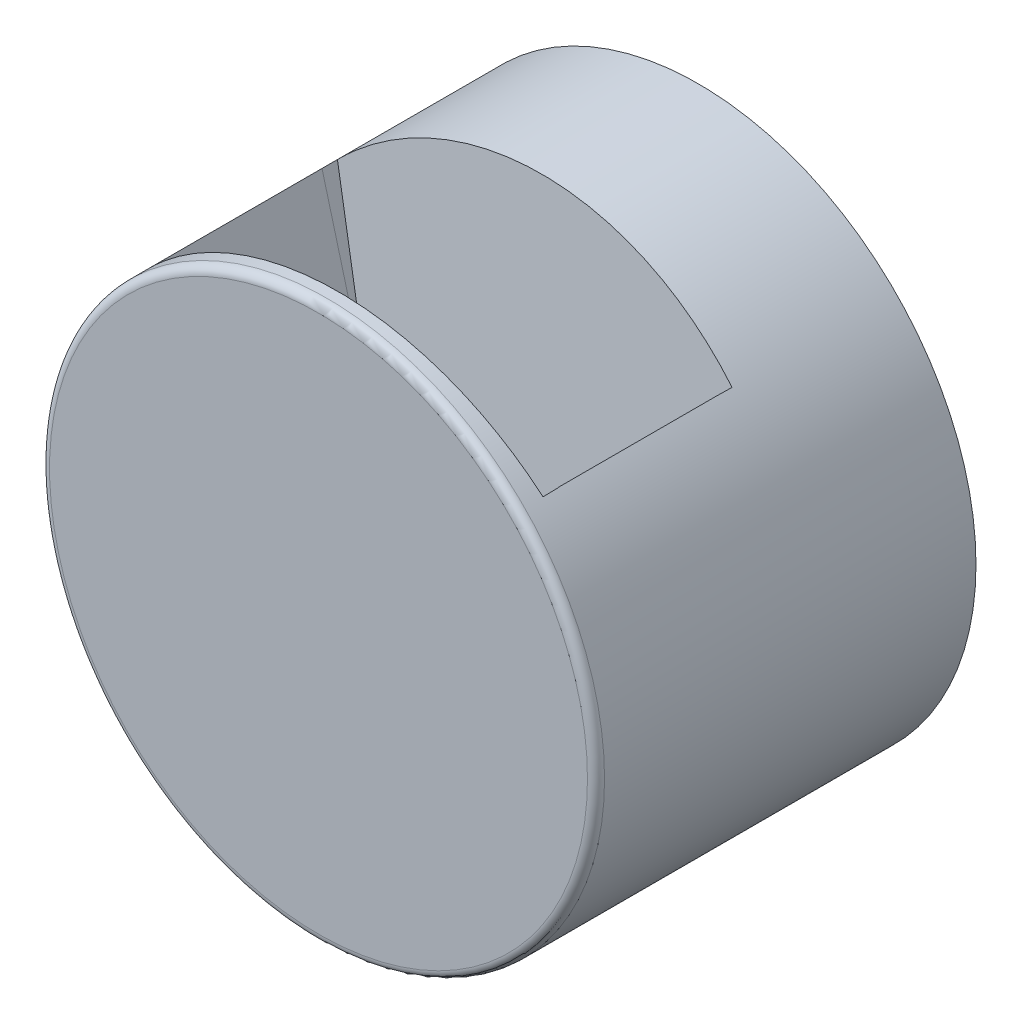
from build123d import *

# Parameters (mm, degrees)
SKETCH_2_R           = 32.5
EXTRUDE_1_DEPTH      = 3
EXTRUDE_START        = 43.5
SKETCH_3_R           = 32.5
SKETCH_3_R_2         = 30.5
EXTRUDE_2_DEPTH      = 43.5
SKETCH_4_W           = 35
SKETCH_4_H           = 18.5
CUT_EXTRUDE_1_DEPTH  = 52
EXTRUDE_3_REACH      = 93.83
EXTRUDE_3_END_RADIUS = 30.5
SKETCH_5_W           = 41
SKETCH_5_H           = 22.5
SKETCH_5_W_2         = 35
SKETCH_5_H_2         = 18.5
SKETCH_9_W           = 43.61428081
SKETCH_9_H           = 23.224697296
CUT_EXTRUDE_2_DEPTH  = 2
EXTRUDE_4_DEPTH      = 22.5
SKETCH_11_W          = 18.5
SKETCH_11_H          = 36.291622976
CUT_REVOLVE_1_ANGLE  = 15
SKETCH_12_W          = 18.5
SKETCH_12_H          = 37.014975327
CUT_REVOLVE_2_ANGLE  = 15
CUT_REVOLVE_3_ANGLE  = 5
CUT_REVOLVE_4_ANGLE  = 5
EXTRUDE_START_2      = 3
EXTRUDE_5_DEPTH      = 3
SKETCH_17_W          = 36.670628391
SKETCH_17_H          = 24.683517756
CUT_EXTRUDE_3_DEPTH  = 3
CHAMFER_1_SIZE       = 4
FILLET_1_R           = 1
EXTRUDE_6_REACH      = 67.382
SKETCH_18_R          = 3
SKETCH_19_R          = 3
EXTRUDE_7_DEPTH      = 18
SKETCH_20_R          = 0.95
CUT_EXTRUDE_4_DEPTH  = 10
SKETCH_21_R          = 44.197984087
CUT_EXTRUDE_5_DEPTH  = 2


with BuildPart() as part:
    # 草图2 → 凸台-拉伸1 (new body)
    with BuildSketch(Plane.XY.offset(76.5)):
        Circle(SKETCH_2_R)
    extrude(amount=EXTRUDE_1_DEPTH)

    # 草图3 → 凸台-拉伸2 (add)
    with BuildSketch(Plane(origin=(0, 0, 76.5), x_dir=(-1, 0, 0), z_dir=(0, 0, -1)).offset(EXTRUDE_START)):
        Circle(SKETCH_3_R)
        Circle(SKETCH_3_R_2, mode=Mode.SUBTRACT)
    extrude(amount=-EXTRUDE_2_DEPTH)

    # 草图4 → 切除-拉伸1 (cut)
    with BuildSketch(Plane(origin=(0, 0, 0), x_dir=(1, 0, 0), z_dir=(0, 1, 0))):
        with Locations((0, -65.25)):
            Rectangle(SKETCH_4_W, SKETCH_4_H)
    extrude(amount=CUT_EXTRUDE_1_DEPTH, mode=Mode.SUBTRACT)

    # 凸台-拉伸3: up to this cylinder (the profile starts inside it)
    extrude_3_end = Plane(origin=(0, 0, 54.46768), z_dir=(0, 0, 1)) * Cylinder(EXTRUDE_3_END_RADIUS, 249.66, mode=Mode.PRIVATE)
    # 草图5 → 凸台-拉伸3 (add, up to the surface)
    with BuildSketch(Plane(origin=(0, 0, 0), x_dir=(1, 0, 0), z_dir=(0, 1, 0)), mode=Mode.PRIVATE) as extrude_3_sk1:
        with Locations((0, -65.25)):
            Rectangle(SKETCH_5_W, SKETCH_5_H)
        with Locations((0, -65.25)):
            Rectangle(SKETCH_5_W_2, SKETCH_5_H_2, mode=Mode.SUBTRACT)
    extrude_3_tool1 = extrude(extrude_3_sk1.sketch, amount=EXTRUDE_3_REACH, mode=Mode.PRIVATE) & extrude_3_end
    add(extrude_3_tool1.solids().sort_by_distance((0, 0, 54.46768))[0])

    # 草图9 → 切除-拉伸2 (cut)
    with BuildSketch(Plane.XZ):
        with Locations((0, 64.887651352)):
            Rectangle(SKETCH_9_W, SKETCH_9_H)
    extrude(amount=-CUT_EXTRUDE_2_DEPTH, mode=Mode.SUBTRACT)

    # 草图10 → 凸台-拉伸4 (add)
    with BuildSketch(Plane(origin=(0, 0, 54), x_dir=(-1, 0, 0), z_dir=(0, 0, -1))):
        with BuildLine():
            Line((20.5, 2), (30.434355587, 2))
            ThreePointArc((30.434355587, 2), (27.468053538, 13.257301189), (20.5, 22.583179581))
            Line((20.5, 22.583179581), (20.5, 2))
        make_face()
        with BuildLine():
            Line((-20.5, 2), (-30.434355587, 2))
            ThreePointArc((-30.434355587, 2), (-27.468053538, 13.257301189), (-20.5, 22.583179581))
            Line((-20.5, 22.583179581), (-20.5, 2))
        make_face()
    extrude(amount=-EXTRUDE_4_DEPTH)

    # 草图11 → 切除-旋转1 (revolve, cut)
    with BuildSketch(Plane.ZY.offset(-17.5)):
        with Locations((65.25, 20.145811488)):
            Rectangle(SKETCH_11_W, SKETCH_11_H)
    revolve(axis=Axis((17.5, 2, 81.98075626), (0, 0, -1)), revolution_arc=CUT_REVOLVE_1_ANGLE, mode=Mode.SUBTRACT)

    # 草图12 → 切除-旋转2 (revolve, cut)
    with BuildSketch(Plane(origin=(-17.5, 0, 0), x_dir=(0, 0, -1), z_dir=(1, 0, 0))):
        with Locations((-65.25, 20.507487664)):
            Rectangle(SKETCH_12_W, SKETCH_12_H)
    revolve(axis=Axis((-17.5, 2, 82.239096386), (0, 0, 1)), revolution_arc=CUT_REVOLVE_2_ANGLE, mode=Mode.SUBTRACT)

    # 草图13 → 切除-旋转3 (revolve, cut)
    with BuildSketch(Plane.XY.offset(56)):
        Polygon((-17.5, 2), (17.5, 2), (26.341893189, 34.998394615), (-26.341893189, 34.998394615), align=None)
    revolve(axis=Axis((-38.580818274, 2, 56), (-1, 0, 0)), revolution_arc=CUT_REVOLVE_3_ANGLE, mode=Mode.SUBTRACT)

    # 草图14 → 切除-旋转4 (revolve, cut)
    with BuildSketch(Plane(origin=(0, 0, 74.5), x_dir=(-1, 0, 0), z_dir=(0, 0, -1))):
        Polygon((17.5, 2), (-17.5, 2), (-26.592656258, 35.805125046), (26.592656258, 35.805125046), align=None)
    revolve(axis=Axis((-42.793281967, 2, 74.5), (1, 0, 0)), revolution_arc=CUT_REVOLVE_4_ANGLE, mode=Mode.SUBTRACT)

    # 草图15 → 凸台-拉伸5 (add)
    with BuildSketch(Plane(origin=(0, 0, 54), x_dir=(-1, 0, 0), z_dir=(0, 0, -1)).offset(EXTRUDE_START_2)):
        with BuildLine():
            Line((30.434355587, 2), (-30.434355587, 2))
            ThreePointArc((-30.434355587, 2), (0, 30.5), (30.434355587, 2))
        make_face()
    extrude(amount=-EXTRUDE_5_DEPTH)

    # 草图17 → 切除-拉伸3 (cut)
    with BuildSketch(Plane(origin=(0, 4.877341222, 55.748265262), x_dir=(1, 0, 0), z_dir=(0, 0.08715574274765839, 0.9961946980917457))):
        with Locations((0.24825377, 21.222934692)):
            Rectangle(SKETCH_17_W, SKETCH_17_H)
    extrude(amount=CUT_EXTRUDE_3_DEPTH, mode=Mode.SUBTRACT)

    # 倒角1
    chamfer_1_edges = [part.edges().sort_by_distance(p)[0] for p in [
        (0, 2, 51),
    ]]
    chamfer(chamfer_1_edges, length=CHAMFER_1_SIZE)

    # 圆角1
    fillet_1_edges = [part.edges().sort_by_distance(p)[0] for p in [
        (-32.5, 0, 79.5),
    ]]
    fillet(fillet_1_edges, radius=FILLET_1_R)

    # 凸台-拉伸6: up to this face of the body (flat: up to its plane)
    extrude_6_end = Plane(part.part.faces().sort_by_distance((0, -11.870804721, 76.5))[0])
    # 草图18 → 凸台-拉伸6 (add, up to the picked face)
    with BuildSketch(Plane(origin=(0, 0, 33), x_dir=(-1, 0, 0), z_dir=(0, 0, -1)), mode=Mode.PRIVATE) as extrude_6_sk1:
        with Locations((-29.5, 0)):
            Circle(SKETCH_18_R)
    extrude_6_tool1 = split(extrude(extrude_6_sk1.sketch, amount=-EXTRUDE_6_REACH, mode=Mode.PRIVATE), bisect_by=extrude_6_end, keep=Keep.BOTH, mode=Mode.PRIVATE)
    # 草图18 → 凸台-拉伸6 (add, up to the picked face)
    with BuildSketch(Plane(origin=(0, 0, 33), x_dir=(-1, 0, 0), z_dir=(0, 0, -1)), mode=Mode.PRIVATE) as extrude_6_sk2:
        with Locations((0, -29.5)):
            Circle(SKETCH_18_R)
    extrude_6_tool2 = split(extrude(extrude_6_sk2.sketch, amount=-EXTRUDE_6_REACH, mode=Mode.PRIVATE), bisect_by=extrude_6_end, keep=Keep.BOTH, mode=Mode.PRIVATE)
    # 草图18 → 凸台-拉伸6 (add, up to the picked face)
    with BuildSketch(Plane(origin=(0, 0, 33), x_dir=(-1, 0, 0), z_dir=(0, 0, -1)), mode=Mode.PRIVATE) as extrude_6_sk3:
        with Locations((29.5, 0)):
            Circle(SKETCH_18_R)
    extrude_6_tool3 = split(extrude(extrude_6_sk3.sketch, amount=-EXTRUDE_6_REACH, mode=Mode.PRIVATE), bisect_by=extrude_6_end, keep=Keep.BOTH, mode=Mode.PRIVATE)
    add(extrude_6_tool1.solids().sort_by(Axis((29.5, 0, 33), (0, 0, 1)))[0])
    add(extrude_6_tool2.solids().sort_by(Axis((0, -29.5, 33), (0, 0, 1)))[0])
    add(extrude_6_tool3.solids().sort_by(Axis((-29.5, 0, 33), (0, 0, 1)))[0])

    # 草图19 → 凸台-拉伸7 (add)
    with BuildSketch(Plane(origin=(0, 0, 33), x_dir=(-1, 0, 0), z_dir=(0, 0, -1))):
        with Locations((0, 29.5)):
            Circle(SKETCH_19_R)
    extrude(amount=-EXTRUDE_7_DEPTH)

    # 草图20 → 切除-拉伸4 (cut)
    with BuildSketch(Plane(origin=(0, 0, 33), x_dir=(-1, 0, 0), z_dir=(0, 0, -1))):
        with Locations((0, -29.5)):
            Circle(SKETCH_20_R)
        with Locations((29.5, 0)):
            Circle(SKETCH_20_R)
        with Locations((0, 29.5)):
            Circle(SKETCH_20_R)
        with Locations((-29.5, 0)):
            Circle(SKETCH_20_R)
    extrude(amount=-CUT_EXTRUDE_4_DEPTH, mode=Mode.SUBTRACT)

    # 草图21 → 切除-拉伸5 (cut)
    with BuildSketch(Plane(origin=(0, 0, 33), x_dir=(-1, 0, 0), z_dir=(0, 0, -1))):
        Circle(SKETCH_21_R)
    extrude(amount=-CUT_EXTRUDE_5_DEPTH, mode=Mode.SUBTRACT)


solid = part.part
